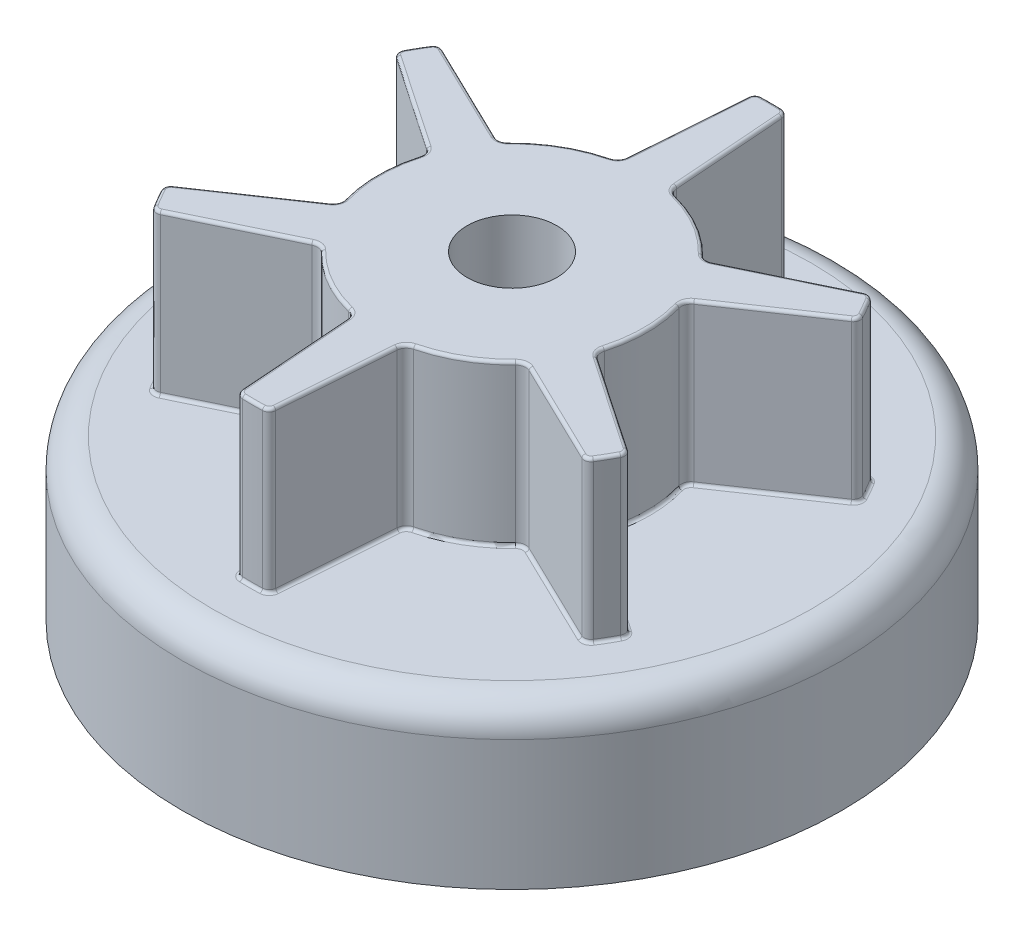
from build123d import *

# Parameters (mm, degrees)
SKETCH1_R           = 33
BOSS_EXTRUDE1_DEPTH = 16
SHELL1_T            = -1.5
FILLET1_R           = 3
BOSS_EXTRUDE2_DEPTH = 16
FILLET2_R           = 0.3
SKETCH3_R           = 4.5
CUT_EXTRUDE1_DEPTH  = 17.5
SKETCH4_R           = 5.5
SKETCH4_R_2         = 4.5
BOSS_EXTRUDE3_DEPTH = 2
FILLET3_R           = 0.3


with BuildPart() as part:
    # Sketch1 → Boss-Extrude1 (new body)
    with BuildSketch(Plane(origin=(0, 0, 0), x_dir=(1, 0, 0), z_dir=(0, 1, 0))):
        with Locations(Location((0, 0, 0), (0, 0, 270))):
            Circle(SKETCH1_R)
    extrude(amount=BOSS_EXTRUDE1_DEPTH)

    # Shell1
    shell1_openings = [part.faces().sort_by_distance(p)[0] for p in [
        (0, 0, 0),
    ]]
    offset(amount=SHELL1_T, openings=shell1_openings, kind=Kind.INTERSECTION)

    # Fillet1
    fillet1_edges = [part.edges().sort_by_distance(p)[0] for p in [
        (0, 16, -33),
        (0, 14.5, -31.5),
    ]]
    fillet(fillet1_edges, radius=FILLET1_R)

    # Sketch2 → Boss-Extrude2 (add)
    with BuildSketch(Plane(origin=(0, 16, 0), x_dir=(1, 0, 0), z_dir=(0, 1, 0))):
        with BuildLine():
            Line((1.671212693, 25.332333425), (2.5, 13.998976054))
            ThreePointArc((2.5, 13.998976054), (2.732558037, 13.427616475), (3.256141172, 13.101432924))
            ThreePointArc((3.256141172, 13.101432924), (6.75, 11.691342951), (9.718103152, 9.370617435))
            ThreePointArc((9.718103152, 9.370617435), (10.262377962, 9.080272915), (10.87346889, 9.164551537))
            Line((10.87346889, 9.164551537), (21.102837936, 14.11347936))
            ThreePointArc((21.102837936, 14.11347936), (21.600510802, 14.156269142), (22, 13.856406461))
            ThreePointArc((22, 13.856406461), (22.516660498, 13), (23, 12.124355653))
            ThreePointArc((23, 12.124355653), (23.059944101, 11.628456518), (22.77405063, 11.218854065))
            Line((22.77405063, 11.218854065), (13.37346889, 4.834424518))
            ThreePointArc((13.37346889, 4.834424518), (12.994935998, 4.347343561), (12.974244324, 3.730815489))
            ThreePointArc((12.974244324, 3.730815489), (13.5, 0), (12.974244324, -3.730815489))
            ThreePointArc((12.974244324, -3.730815489), (12.994935998, -4.347343561), (13.37346889, -4.834424518))
            Line((13.37346889, -4.834424518), (22.77405063, -11.218854065))
            ThreePointArc((22.77405063, -11.218854065), (23.059944101, -11.628456518), (23, -12.124355653))
            ThreePointArc((23, -12.124355653), (22.516660498, -13), (22, -13.856406461))
            ThreePointArc((22, -13.856406461), (21.600510802, -14.156269142), (21.102837936, -14.11347936))
            Line((21.102837936, -14.11347936), (10.87346889, -9.164551537))
            ThreePointArc((10.87346889, -9.164551537), (10.262377962, -9.080272915), (9.718103152, -9.370617435))
            ThreePointArc((9.718103152, -9.370617435), (6.75, -11.691342951), (3.256141172, -13.101432924))
            ThreePointArc((3.256141172, -13.101432924), (2.732558037, -13.427616475), (2.5, -13.998976054))
            Line((2.5, -13.998976054), (1.671212693, -25.332333425))
            ThreePointArc((1.671212693, -25.332333425), (1.459433299, -25.78472566), (1, -25.980762114))
            ThreePointArc((1, -25.980762114), (0, -26), (-1, -25.980762114))
            ThreePointArc((-1, -25.980762114), (-1.459433299, -25.78472566), (-1.671212693, -25.332333425))
            Line((-1.671212693, -25.332333425), (-2.5, -13.998976054))
            ThreePointArc((-2.5, -13.998976054), (-2.732558037, -13.427616475), (-3.256141172, -13.101432924))
            ThreePointArc((-3.256141172, -13.101432924), (-6.75, -11.691342951), (-9.718103152, -9.370617435))
            ThreePointArc((-9.718103152, -9.370617435), (-10.262377962, -9.080272915), (-10.87346889, -9.164551537))
            Line((-10.87346889, -9.164551537), (-21.102837936, -14.11347936))
            ThreePointArc((-21.102837936, -14.11347936), (-21.600510802, -14.156269142), (-22, -13.856406461))
            ThreePointArc((-22, -13.856406461), (-22.516660498, -13), (-23, -12.124355653))
            ThreePointArc((-23, -12.124355653), (-23.059944101, -11.628456518), (-22.77405063, -11.218854065))
            Line((-22.77405063, -11.218854065), (-13.37346889, -4.834424518))
            ThreePointArc((-13.37346889, -4.834424518), (-12.994935998, -4.347343561), (-12.974244324, -3.730815489))
            ThreePointArc((-12.974244324, -3.730815489), (-13.5, 0), (-12.974244324, 3.730815489))
            ThreePointArc((-12.974244324, 3.730815489), (-12.994935998, 4.347343561), (-13.37346889, 4.834424518))
            Line((-13.37346889, 4.834424518), (-22.77405063, 11.218854065))
            ThreePointArc((-22.77405063, 11.218854065), (-23.059944101, 11.628456518), (-23, 12.124355653))
            ThreePointArc((-23, 12.124355653), (-22.516660498, 13), (-22, 13.856406461))
            ThreePointArc((-22, 13.856406461), (-21.600510802, 14.156269142), (-21.102837936, 14.11347936))
            Line((-21.102837936, 14.11347936), (-10.87346889, 9.164551537))
            ThreePointArc((-10.87346889, 9.164551537), (-10.262377962, 9.080272915), (-9.718103152, 9.370617435))
            ThreePointArc((-9.718103152, 9.370617435), (-6.75, 11.691342951), (-3.256141172, 13.101432924))
            ThreePointArc((-3.256141172, 13.101432924), (-2.732558037, 13.427616475), (-2.5, 13.998976054))
            Line((-2.5, 13.998976054), (-1.671212693, 25.332333425))
            ThreePointArc((-1.671212693, 25.332333425), (-1.459433299, 25.78472566), (-1, 25.980762114))
            ThreePointArc((-1, 25.980762114), (0, 26), (1, 25.980762114))
            ThreePointArc((1, 25.980762114), (1.459433299, 25.78472566), (1.671212693, 25.332333425))
        make_face()
    extrude(amount=BOSS_EXTRUDE2_DEPTH)

    # Fillet2
    fillet2_edges = [part.edges().sort_by_distance(p)[0] for p in [
        (-2.732558037, 16, -13.427616475),
        (-6.75, 16, -11.691342951),
        (-10.262377962, 16, -9.080272915),
        (-15.988153413, 16, -11.639015448),
        (-21.600510802, 16, -14.156269142),
        (-22.516660498, 16, -13),
        (-23.059944101, 16, -11.628456518),
        (-18.07375976, 16, -8.026639291),
        (-12.994935998, 16, -4.347343561),
        (-13.5, 16, 0),
        (-12.994935998, 16, 4.347343561),
        (-18.07375976, 16, 8.026639291),
        (-23.059944101, 16, 11.628456518),
        (-22.516660498, 16, 13),
        (-21.600510802, 16, 14.156269142),
        (-15.988153413, 16, 11.639015448),
        (-10.262377962, 16, 9.080272915),
        (-6.75, 16, 11.691342951),
        (-2.732558037, 16, 13.427616475),
        (-2.085606347, 16, 19.665654739),
        (-1.459433299, 16, 25.78472566),
        (0, 16, 26),
        (1.459433299, 16, 25.78472566),
        (2.085606347, 16, 19.665654739),
        (2.732558037, 16, 13.427616475),
        (6.75, 16, 11.691342951),
        (10.262377962, 16, 9.080272915),
        (15.988153413, 16, 11.639015448),
        (21.600510802, 16, 14.156269142),
        (22.516660498, 16, 13),
        (23.059944101, 16, 11.628456518),
        (18.07375976, 16, 8.026639291),
        (12.994935998, 16, 4.347343561),
        (13.5, 16, 0),
        (12.994935998, 16, -4.347343561),
        (18.07375976, 16, -8.026639291),
        (23.059944101, 16, -11.628456518),
        (22.516660498, 16, -13),
        (21.600510802, 16, -14.156269142),
        (15.988153413, 16, -11.639015448),
        (10.262377962, 16, -9.080272915),
        (6.75, 16, -11.691342951),
        (2.732558037, 16, -13.427616475),
        (2.085606347, 16, -19.665654739),
        (1.459433299, 16, -25.78472566),
        (0, 16, -26),
        (-1.459433299, 16, -25.78472566),
        (-2.085606347, 16, -19.665654739),
        (-2.732558037, 32, -13.427616475),
        (-6.75, 32, -11.691342951),
        (-10.262377962, 32, -9.080272915),
        (-15.988153413, 32, -11.639015448),
        (-21.600510802, 32, -14.156269142),
        (-22.516660498, 32, -13),
        (-23.059944101, 32, -11.628456518),
        (-18.07375976, 32, -8.026639291),
        (-12.994935998, 32, -4.347343561),
        (-13.5, 32, 0),
        (-12.994935998, 32, 4.347343561),
        (-18.07375976, 32, 8.026639291),
        (-23.059944101, 32, 11.628456518),
        (-22.516660498, 32, 13),
        (-21.600510802, 32, 14.156269142),
        (-15.988153413, 32, 11.639015448),
        (-10.262377962, 32, 9.080272915),
        (-6.75, 32, 11.691342951),
        (-2.732558037, 32, 13.427616475),
        (-2.085606347, 32, 19.665654739),
        (-1.459433299, 32, 25.78472566),
        (0, 32, 26),
        (1.459433299, 32, 25.78472566),
        (2.085606347, 32, 19.665654739),
        (2.732558037, 32, 13.427616475),
        (6.75, 32, 11.691342951),
        (10.262377962, 32, 9.080272915),
        (15.988153413, 32, 11.639015448),
        (21.600510802, 32, 14.156269142),
        (22.516660498, 32, 13),
        (23.059944101, 32, 11.628456518),
        (18.07375976, 32, 8.026639291),
        (12.994935998, 32, 4.347343561),
        (13.5, 32, 0),
        (12.994935998, 32, -4.347343561),
        (18.07375976, 32, -8.026639291),
        (23.059944101, 32, -11.628456518),
        (22.516660498, 32, -13),
        (21.600510802, 32, -14.156269142),
        (15.988153413, 32, -11.639015448),
        (10.262377962, 32, -9.080272915),
        (6.75, 32, -11.691342951),
        (2.732558037, 32, -13.427616475),
        (2.085606347, 32, -19.665654739),
        (1.459433299, 32, -25.78472566),
        (0, 32, -26),
        (-1.459433299, 32, -25.78472566),
        (-2.085606347, 32, -19.665654739),
    ]]
    fillet(fillet2_edges, radius=FILLET2_R)

    # Sketch3 → Cut-Extrude1 (cut)
    with BuildSketch(Plane.XZ.offset(-14.5)):
        with Locations(Location((0, 0, 0), (0, 0, 270))):
            Circle(SKETCH3_R)
    extrude(amount=-CUT_EXTRUDE1_DEPTH, mode=Mode.SUBTRACT)

    # Sketch4 → Boss-Extrude3 (add)
    with BuildSketch(Plane.XZ.offset(-14.5)):
        with Locations(Location((0, 0, 0), (0, 0, 90))):
            Circle(SKETCH4_R)
        with Locations(Location((0, 0, 0), (0, 0, 270))):
            Circle(SKETCH4_R_2, mode=Mode.SUBTRACT)
    extrude(amount=BOSS_EXTRUDE3_DEPTH)

    # Fillet3
    fillet3_edges = [part.edges().sort_by_distance(p)[0] for p in [
        (0, 14.5, -5.5),
        (0, 12.5, 4.5),
        (0, 12.5, -5.5),
    ]]
    fillet(fillet3_edges, radius=FILLET3_R)


solid = part.part
